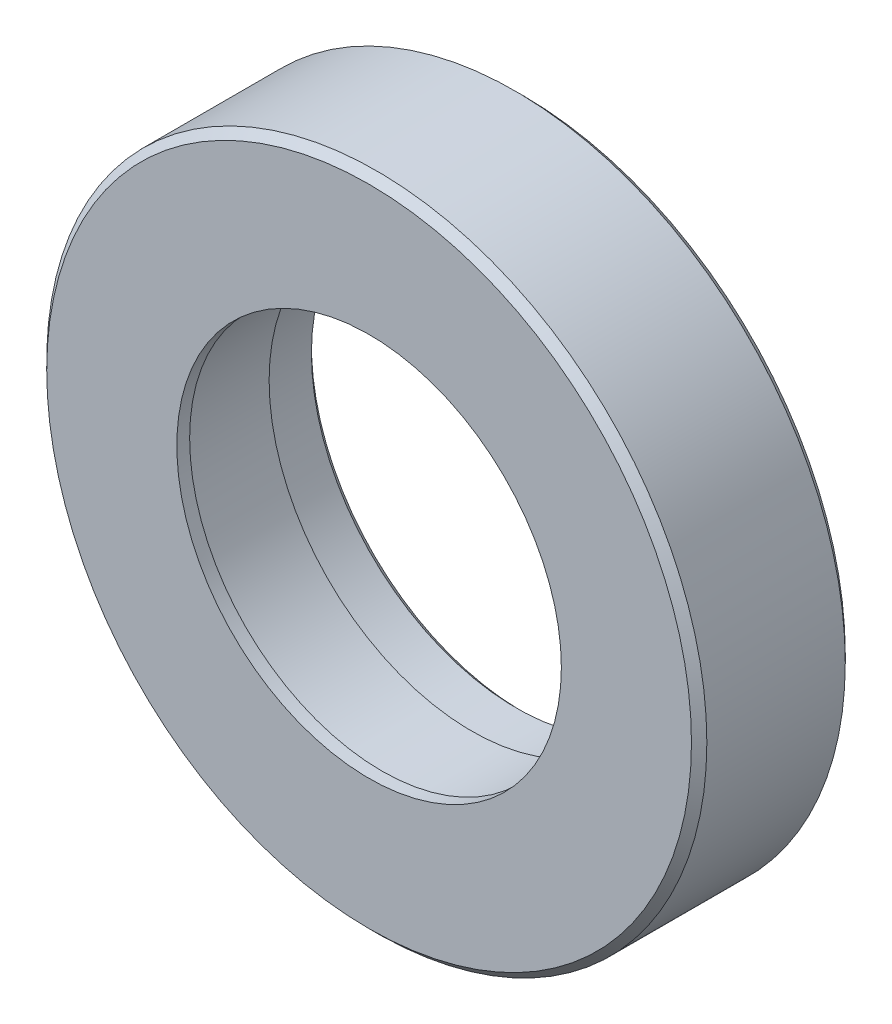
from build123d import *

# Parameters (mm, degrees)
SKETCH1_R           = 25.75
BOSS_EXTRUDE1_DEPTH = 12
CHAMFER1_SIZE       = 0.6
SKETCH2_R           = 15
CUT_EXTRUDE1_DEPTH  = 13
SKETCH3_R           = 15.8
CUT_EXTRUDE2_DEPTH  = 11
SKETCH4_R           = 16
CUT_EXTRUDE3_DEPTH  = 4
CHAMFER2_SIZE       = 0.5


with BuildPart() as part:
    # Sketch1 → Boss-Extrude1 (new body)
    with BuildSketch(Plane.XY):
        Circle(SKETCH1_R)
    extrude(amount=BOSS_EXTRUDE1_DEPTH)

    # Chamfer1
    chamfer1_edges = [part.edges().sort_by_distance(p)[0] for p in [
        (-25.75, 0, 0),
        (-25.75, 0, 12),
    ]]
    chamfer(chamfer1_edges, length=CHAMFER1_SIZE)

    # Sketch2 → Cut-Extrude1 (cut, through all)
    with BuildSketch(Plane.XY.offset(12)):
        Circle(SKETCH2_R)
    extrude(amount=-CUT_EXTRUDE1_DEPTH, mode=Mode.SUBTRACT)

    # Sketch3 → Cut-Extrude2 (cut)
    with BuildSketch(Plane(origin=(0, 0, 0), x_dir=(-1, 0, 0), z_dir=(0, 0, -1))):
        Circle(SKETCH3_R)
    extrude(amount=-CUT_EXTRUDE2_DEPTH, mode=Mode.SUBTRACT)

    # Sketch4 → Cut-Extrude3 (cut)
    with BuildSketch(Plane(origin=(0, 0, 0), x_dir=(-1, 0, 0), z_dir=(0, 0, -1))):
        Circle(SKETCH4_R)
    extrude(amount=-CUT_EXTRUDE3_DEPTH, mode=Mode.SUBTRACT)

    # Chamfer2
    chamfer2_edges = [part.edges().sort_by_distance(p)[0] for p in [
        (16, 0, 0),
    ]]
    chamfer(chamfer2_edges, length=CHAMFER2_SIZE)


solid = part.part
